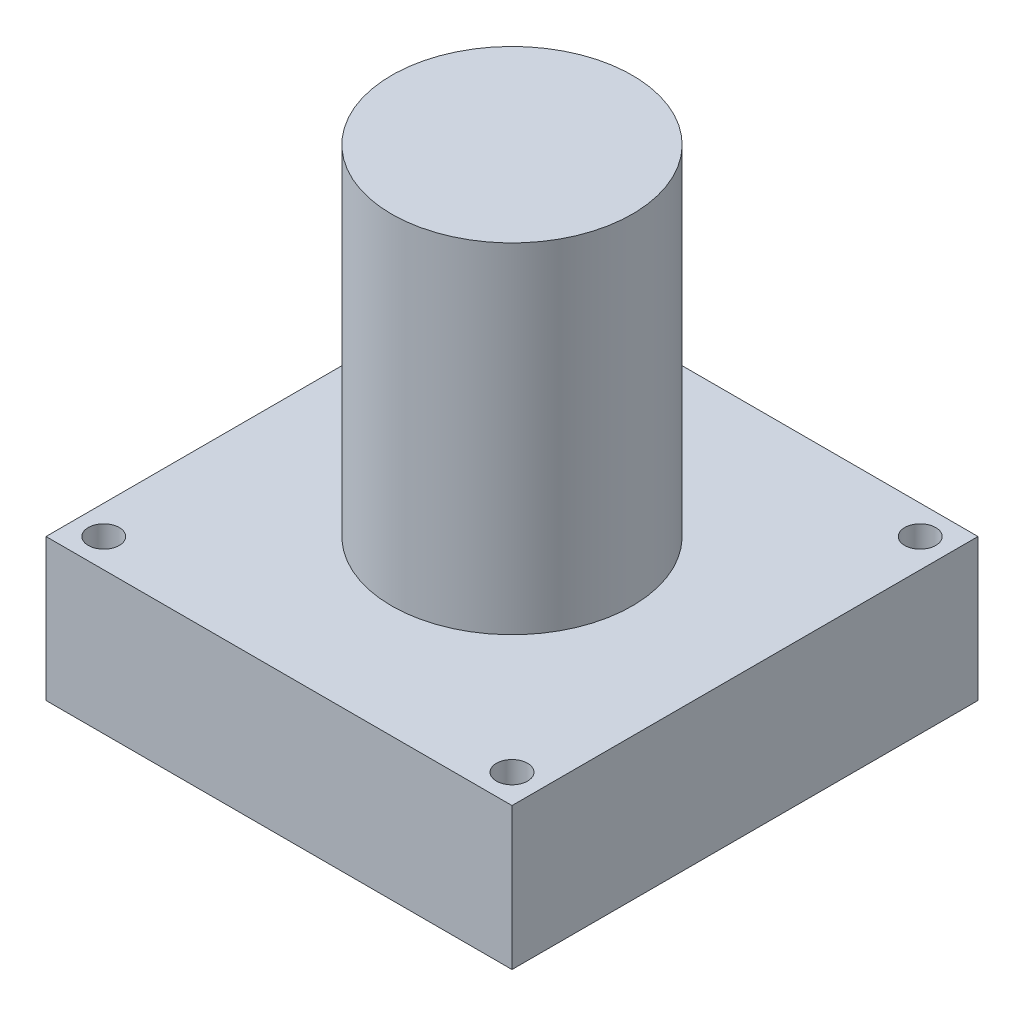
from build123d import *

# Parameters (mm, degrees)
SKETCH1_W           = 30
SKETCH1_H           = 30
SKETCH1_R           = 1
BOSS_EXTRUDE1_DEPTH = 9.144
SKETCH2_R           = 7.747
BOSS_EXTRUDE2_DEPTH = 21.844
SKETCH3_W           = 13.335
SKETCH3_H           = 3.048
BOSS_EXTRUDE3_DEPTH = 6.35


with BuildPart() as part:
    # Sketch1 → Boss-Extrude1 (new body)
    with BuildSketch(Plane(origin=(0, 0, 0), x_dir=(1, 0, 0), z_dir=(0, 1, 0))):
        with Locations((15, 15)):
            Rectangle(SKETCH1_W, SKETCH1_H)
        with Locations((28.14, 1.86)):
            Circle(SKETCH1_R, mode=Mode.SUBTRACT)
        with Locations((28.14, 28.1400088)):
            Circle(SKETCH1_R, mode=Mode.SUBTRACT)
        with Locations((1.86, 28.1400088)):
            Circle(SKETCH1_R, mode=Mode.SUBTRACT)
        with Locations((1.86, 1.86)):
            Circle(SKETCH1_R, mode=Mode.SUBTRACT)
    extrude(amount=BOSS_EXTRUDE1_DEPTH)

    # Sketch2 → Boss-Extrude2 (add)
    with BuildSketch(Plane(origin=(0, 9.144, 0), x_dir=(1, 0, 0), z_dir=(0, 1, 0))):
        with Locations((15, 15)):
            Circle(SKETCH2_R)
    extrude(amount=BOSS_EXTRUDE2_DEPTH)

    # Sketch3 → Boss-Extrude3 (add)
    with BuildSketch(Plane.XZ):
        with Locations((15, -26.19)):
            Rectangle(SKETCH3_W, SKETCH3_H)
    extrude(amount=BOSS_EXTRUDE3_DEPTH)


solid = part.part
